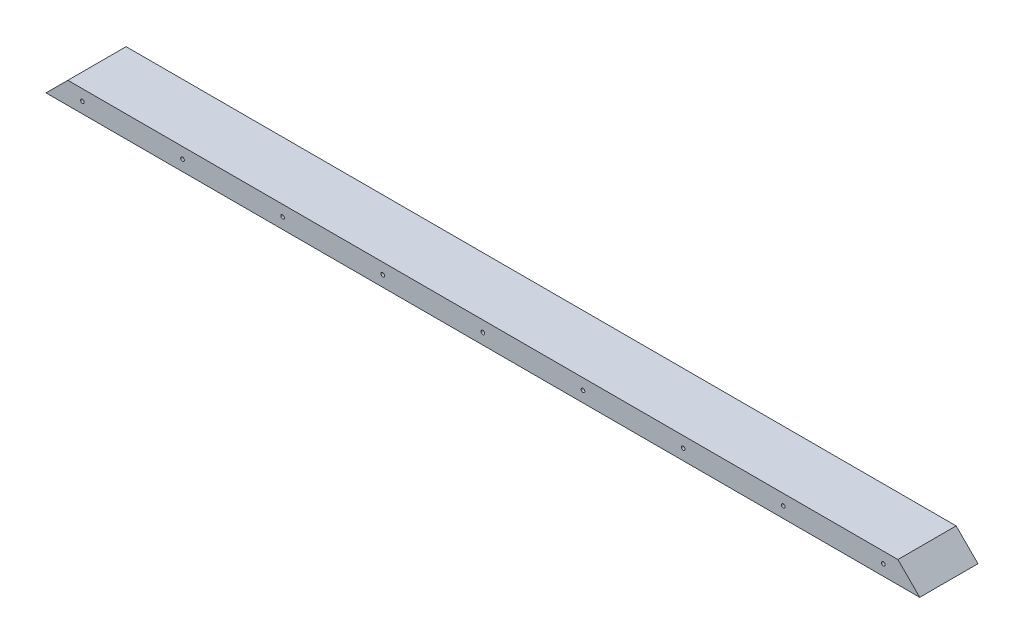
from build123d import *

# Parameters (mm, degrees)
SALIENTE_EXTRUIR1_DEPTH = 600
CROQUIS2_R              = 1.25
CORTAR_EXTRUIR1_DEPTH   = 41


with BuildPart() as part:
    # Croquis1 → Saliente-Extruir1 (new body)
    with BuildSketch(Plane(origin=(0, 0, 0), x_dir=(0, 0, -1), z_dir=(1, 0, 0))):
        Polygon((-20, 0), (20, 0), (20, 15), (18.5, 15), (-18.5, 15), (-20, 15), align=None)
    extrude(amount=SALIENTE_EXTRUIR1_DEPTH)

    # Croquis2 → Cortar-Extruir1 (cut, through all)
    with BuildSketch(Plane(origin=(0, 0, -20), x_dir=(-1, 0, 0), z_dir=(0, 0, -1))):
        with Locations((-25, 7.5)):
            Circle(CROQUIS2_R)
        with Locations((-93.75, 7.5)):
            Circle(CROQUIS2_R)
        with Locations((-162.5, 7.5)):
            Circle(CROQUIS2_R)
        with Locations((-231.25, 7.5)):
            Circle(CROQUIS2_R)
        with Locations((-368.75, 7.5)):
            Circle(CROQUIS2_R)
        with Locations((-437.5, 7.5)):
            Circle(CROQUIS2_R)
        with Locations((-506.25, 7.5)):
            Circle(CROQUIS2_R)
        with Locations((-575, 7.5)):
            Circle(CROQUIS2_R)
        with Locations((-300, 7.5)):
            Circle(CROQUIS2_R)
        Polygon((-600, 15), (-585, 15), (-600, 0), align=None)
        Polygon((0, 15), (-15, 15), (0, 0), align=None)
    extrude(amount=-CORTAR_EXTRUIR1_DEPTH, mode=Mode.SUBTRACT)


solid = part.part
